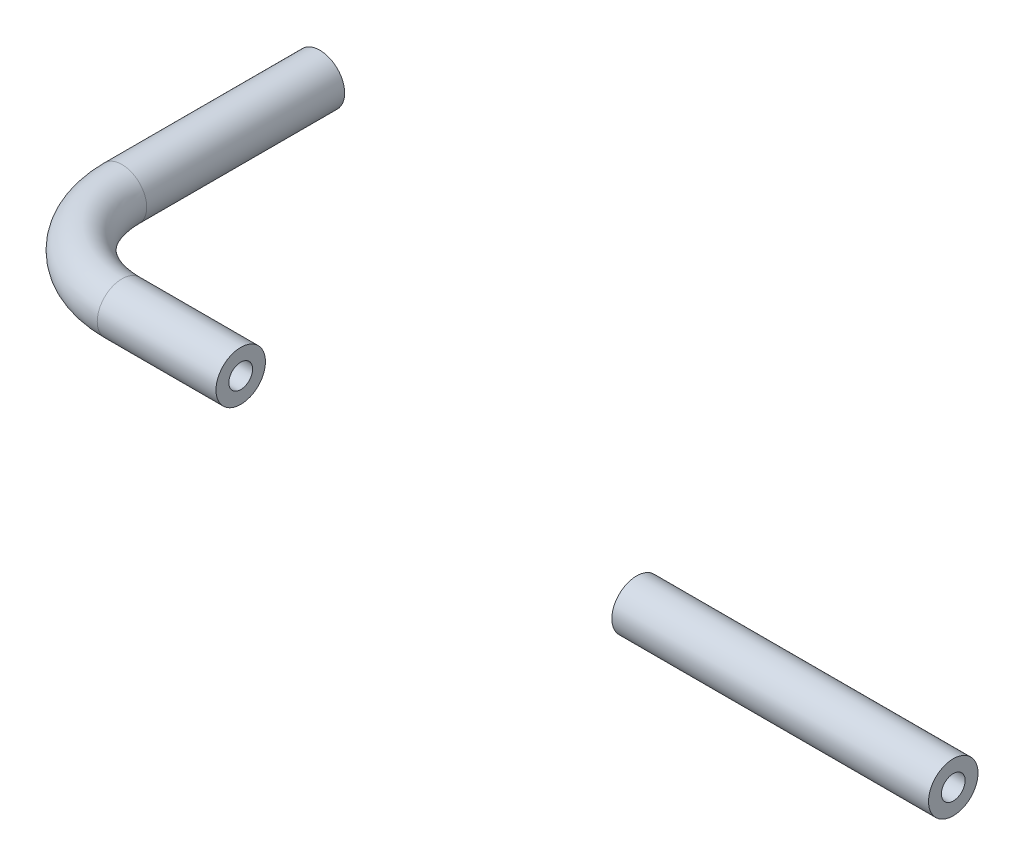
from build123d import *

# Parameters (mm, degrees)
SWEEP_THIN1_PROFILE_R   = 3.175
SWEEP_THIN1_PROFILE_R_2 = 1.524
SWEEP_THIN2_PROFILE_R   = 3.175
SWEEP_THIN2_PROFILE_R_2 = 1.524


with BuildPart() as part:
    # Sweep-Thin1: sweep along a path in Sketch1
    with BuildLine(Plane(origin=(0, 0, 0), x_dir=(1, 0, 0), z_dir=(0, 1, 0))) as sweep_thin1_path:
        Line((-27.94, 38.1), (-27.94, 12.7))
        ThreePointArc((-27.94, 12.7), (-24.220256121, 3.719743879), (-15.24, 0))
        Line((-15.24, 0), (0, 0))
    # Sweep-Thin1 profile (on start of the path) → Sweep-Thin1 (sweep)
    with BuildSketch(Plane(origin=(-27.94, 0, -38.1), x_dir=(1, 0, 0), z_dir=(0, 0, 1))):
        Circle(SWEEP_THIN1_PROFILE_R)
        Circle(SWEEP_THIN1_PROFILE_R_2, mode=Mode.SUBTRACT)
    sweep(path=sweep_thin1_path.line)


with BuildPart() as body_2:
    # Sweep-Thin2: sweep along a path in Sketch15
    with BuildLine(Plane(origin=(0, 0, 0), x_dir=(1, 0, 0), z_dir=(0, 1, 0))) as sweep_thin2_path:
        Line((50.8, 0), (91.44, 0))
    # Sweep-Thin2 profile (on start of the path) → Sweep-Thin2 (sweep)
    with BuildSketch(Plane(origin=(50.8, 0, 0), x_dir=(0, 0, 1), z_dir=(1, 0, 0))):
        Circle(SWEEP_THIN2_PROFILE_R)
        Circle(SWEEP_THIN2_PROFILE_R_2, mode=Mode.SUBTRACT)
    sweep(path=sweep_thin2_path.line)


solid = Compound([part.part, body_2.part])
